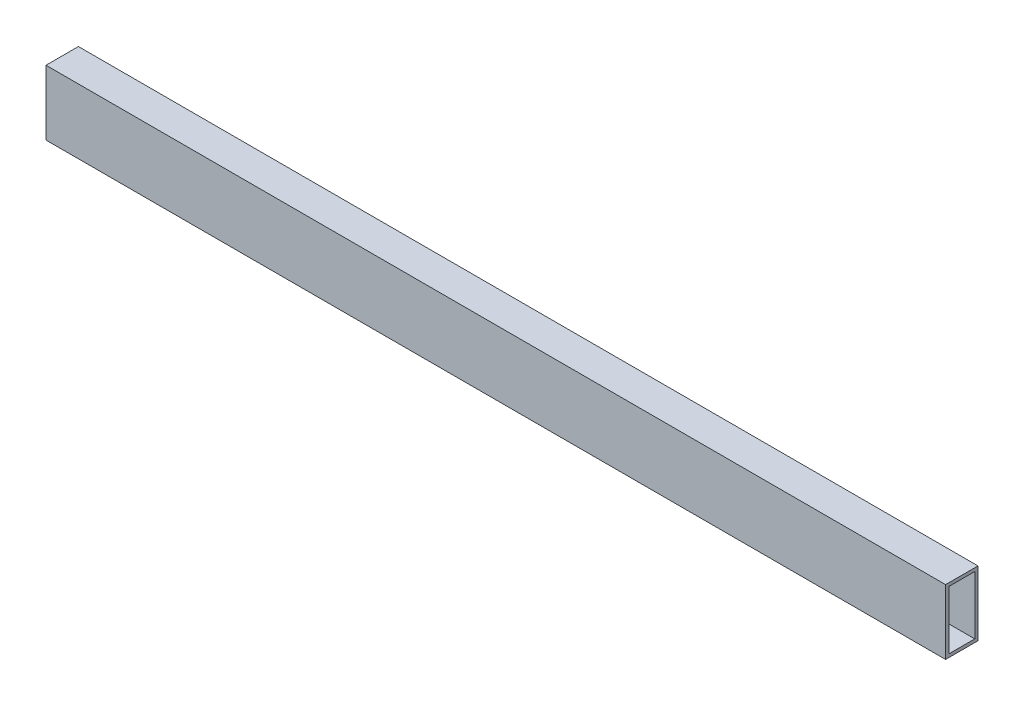
from build123d import *

# Parameters (mm, degrees)
SKETCH1_W           = 25.4
SKETCH1_H           = 50.8
SKETCH1_W_2         = 20.32
SKETCH1_H_2         = 45.72
EXTRUDE_THIN1_DEPTH = 704.85


with BuildPart() as part:
    # Sketch1 → Extrude-Thin1 (new body)
    with BuildSketch(Plane(origin=(0, 0, 0), x_dir=(0, 0, -1), z_dir=(1, 0, 0))):
        Rectangle(SKETCH1_W, SKETCH1_H)
        Rectangle(SKETCH1_W_2, SKETCH1_H_2, mode=Mode.SUBTRACT)
    extrude(amount=EXTRUDE_THIN1_DEPTH)


solid = part.part
